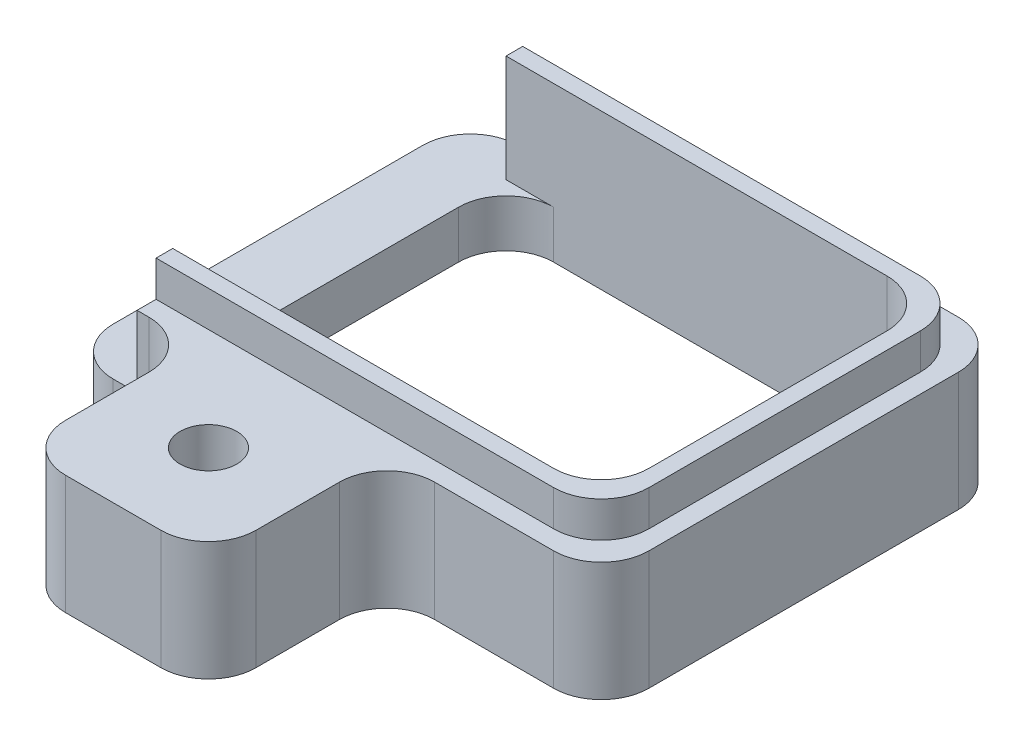
from build123d import *

# Parameters (mm, degrees)
SKETCH5_W                 = 11.25
SKETCH5_H                 = 8.5
EXTRUDE4_DEPTH            = 2.5
SKETCH19_W                = 1.5
SKETCH19_H                = 8.5
EXTRUDE12_DEPTH           = 1.5
SKETCH21_W                = 9
SKETCH21_H                = 7
EXTRUDE13_DEPTH           = 3.5
SKETCH22_W                = 4
SKETCH22_H                = 2.5
EXTRUDE14_DEPTH           = 3.75
EXTRUDE15_DEPTH           = 0.75
F_0_80_TAPPED_HOLE1_D     = 1.19126
F_0_80_TAPPED_HOLE1_DEPTH = 79.01
F_0_80_TAPPED_HOLE1_TIP   = 0.357890611
FILLET4_R                 = 1


with BuildPart() as part:
    # Sketch5 → Extrude4 (new body)
    with BuildSketch(Plane(origin=(0, 0, 0), x_dir=(1, 0, 0), z_dir=(0, 1, 0))):
        Rectangle(SKETCH5_W, SKETCH5_H)
    extrude(amount=EXTRUDE4_DEPTH)

    # Sketch19 → Extrude12 (cut)
    with BuildSketch(Plane(origin=(0, 2.5, 0), x_dir=(-1, 0, 0), z_dir=(0, 1, 0))):
        with Locations((4.875, 0)):
            Rectangle(SKETCH19_W, SKETCH19_H)
    extrude(amount=-EXTRUDE12_DEPTH, mode=Mode.SUBTRACT)

    # Sketch21 → Extrude13 (cut, through all)
    with BuildSketch(Plane(origin=(0, 2.5, 0), x_dir=(-1, 0, 0), z_dir=(0, 1, 0))):
        with Locations((-0.375, 0)):
            Rectangle(SKETCH21_W, SKETCH21_H)
    extrude(amount=-EXTRUDE13_DEPTH, mode=Mode.SUBTRACT)

    # Sketch22 → Extrude14 (add)
    with BuildSketch(Plane.XY.offset(4.25)):
        with Locations((-0.875, 1.25)):
            Rectangle(SKETCH22_W, SKETCH22_H)
    extrude(amount=EXTRUDE14_DEPTH)

    # Sketch24 → Extrude15 (add)
    with BuildSketch(Plane(origin=(0, 2.5, 0), x_dir=(1, 0, 0), z_dir=(0, 1, 0))):
        Polygon((-4.125, 3.85), (-4.125, 3.5), (4.875, 3.5), (4.875, -3.5), (-4.125, -3.5), (-4.125, -3.85), (5.225, -3.85), (5.225, 3.85), align=None)
    extrude(amount=EXTRUDE15_DEPTH)

    # #0-80 Tapped Hole1
    with Locations(Plane(origin=(-0.875, 2.5, 6), x_dir=(0, 0, 1), z_dir=(0, 1, 0))):
        with Locations((0, 0)):
            Hole(F_0_80_TAPPED_HOLE1_D / 2, depth=F_0_80_TAPPED_HOLE1_DEPTH)
            with Locations((0, 0, -(F_0_80_TAPPED_HOLE1_DEPTH + F_0_80_TAPPED_HOLE1_TIP / 2))):  # 118° drill point
                Cone(0, F_0_80_TAPPED_HOLE1_D / 2, F_0_80_TAPPED_HOLE1_TIP, mode=Mode.SUBTRACT)

    # Fillet4
    fillet4_edges = [part.edges().sort_by_distance(p)[0] for p in [
        (5.625, 1.25, -4.25),
        (5.225, 2.875, -3.85),
        (5.625, 1.25, 4.25),
        (5.225, 2.875, 3.85),
        (4.875, 1.625, 3.5),
        (4.875, 1.625, -3.5),
        (-4.125, 0.5, 3.5),
        (-4.125, 0.5, -3.5),
        (-5.625, 0.5, -4.25),
        (-5.625, 0.5, 4.25),
        (-2.875, 1.25, 4.25),
        (-2.875, 1.25, 8),
        (1.125, 1.25, 8),
        (1.125, 1.25, 4.25),
    ]]
    fillet(fillet4_edges, radius=FILLET4_R)


solid = part.part
